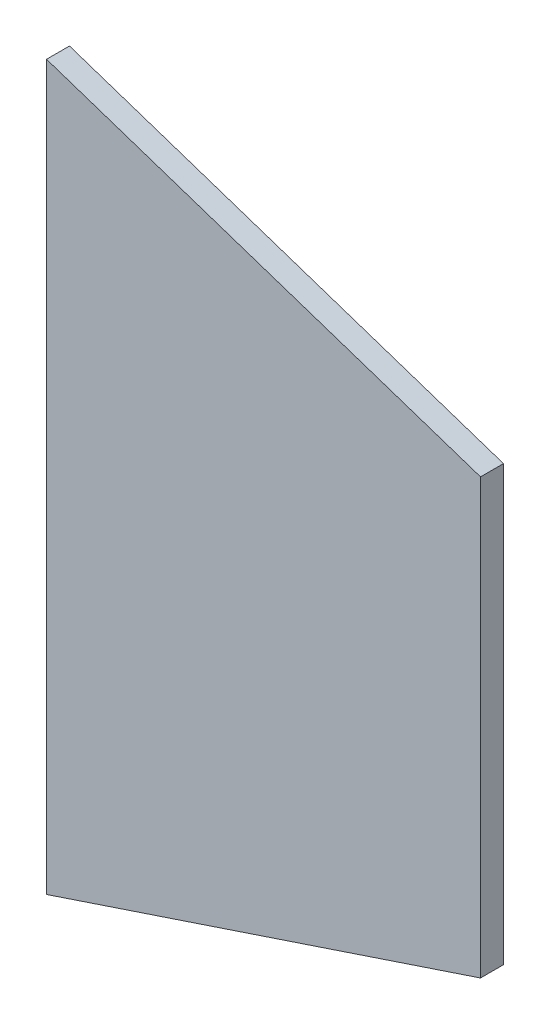
from build123d import *

# Parameters (mm, degrees)
BOSS_EXTRUDE1_DEPTH      = 4.03225
BOSS_EXTRUDE1_DEPTH_BACK = 4.03225


with BuildPart() as part:
    # Sketch1 → Boss-Extrude1 (new, two sides: drawn at the far end of the back side and taken through both)
    with BuildSketch(Plane.XY.offset(-BOSS_EXTRUDE1_DEPTH_BACK)):
        Polygon((95.25, 127), (95.25, -127), (247.65, -76.2), (247.65, 76.2), align=None)
    extrude(amount=BOSS_EXTRUDE1_DEPTH + BOSS_EXTRUDE1_DEPTH_BACK)


solid = part.part
